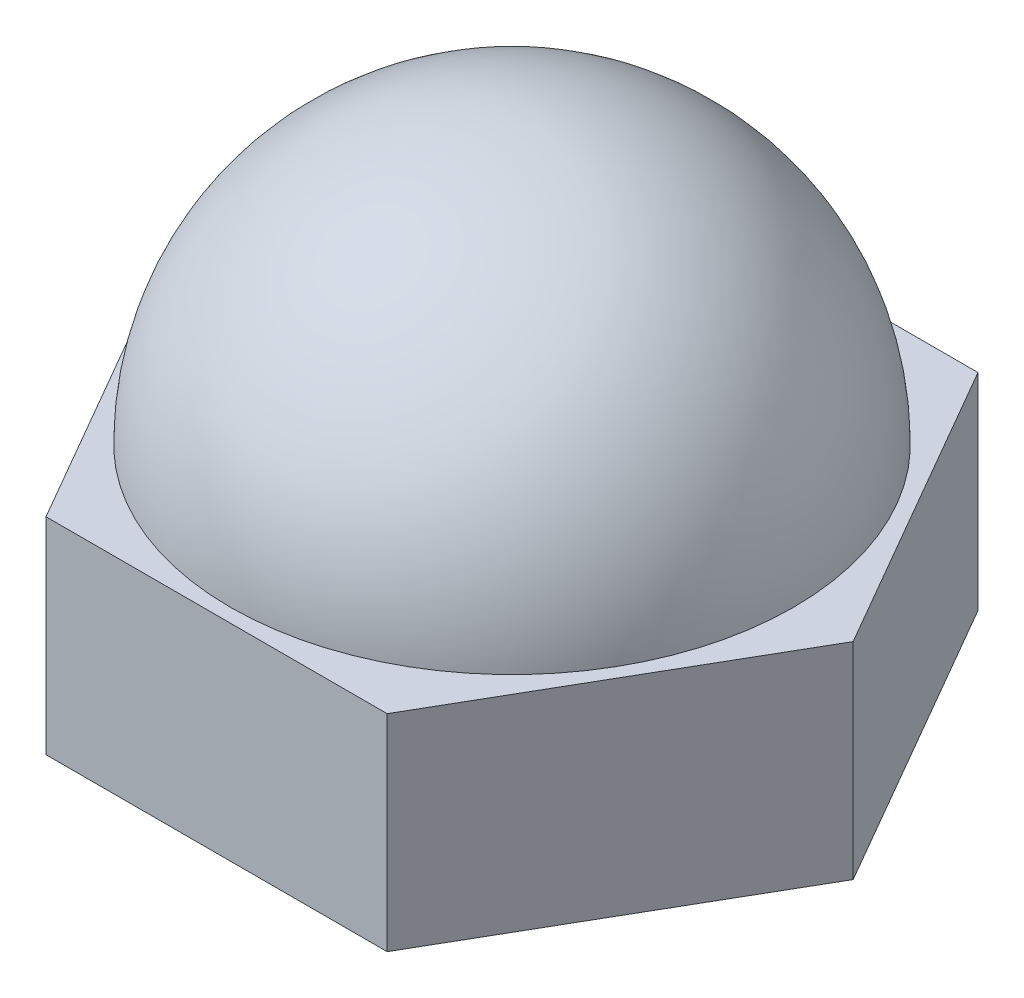
from build123d import *

# Parameters (mm, degrees)
SKETCH1_R           = 4
BOSS_EXTRUDE1_DEPTH = 3


with BuildPart() as part:
    # Sketch1 → Boss-Extrude1 (new body)
    with BuildSketch(Plane(origin=(0, 0, 0), x_dir=(1, 0, 0), z_dir=(0, 1, 0))):
        Polygon((4.965212315, 0), (2.482606158, 4.3), (-2.482606158, 4.3), (-4.965212315, 0), (-2.482606158, -4.3), (2.482606158, -4.3), align=None)
        Circle(SKETCH1_R, mode=Mode.SUBTRACT)
    extrude(amount=BOSS_EXTRUDE1_DEPTH)

    # Sketch2 → Revolve-Thin1 (revolve)
    with BuildSketch(Plane.XY):
        with BuildLine():
            ThreePointArc((0, 7.1), (2.899137803, 5.899137803), (4.1, 3))
            Line((4.1, 3), (0, 3))
            Line((0, 3), (0, 4))
            Line((0, 4), (2.93428015, 4))
            ThreePointArc((2.93428015, 4), (1.804161855, 5.520912533), (0, 6.1))
            Line((0, 6.1), (0, 7.1))
        make_face()
    revolve(axis=Axis((0, 7.455, 0), (0, -1, 0)))


solid = part.part
